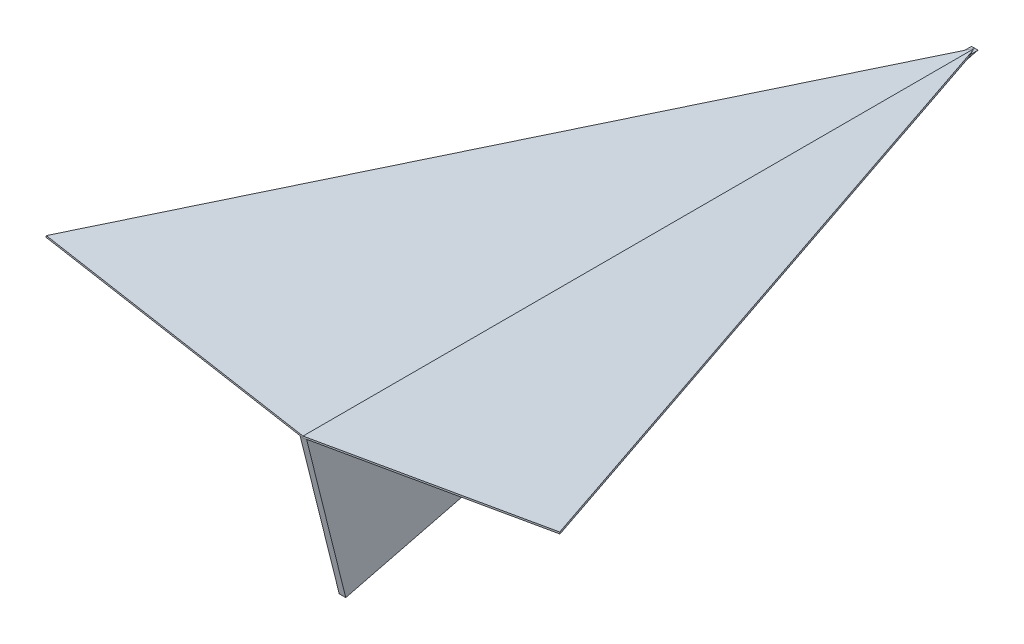
from build123d import *

# Parameters (mm, degrees)
THICKEN_1_T2 = 0.5
THICKEN_2_T2 = 0.5
THICKEN_3_T1 = 1
THICKEN_3_T2 = 1


with BuildPart() as body_1:
    # Sketch 5 → Sheet Plane 1: a flat surface bounded by the sketch
    with BuildSketch(Plane(origin=(0, 0, 0), x_dir=(0, 0, 1), z_dir=(0.17364817766692733, 0.9848077530122086, 0)), mode=Mode.PRIVATE) as sheet_plane_1_1_region:
        Polygon((206.155281281, 0), (206.155281281, -80), (0, 0), align=None)
    sheet_plane_1_1 = sheet_plane_1_1_region.sketch.faces()[0]
    add(Solid.thicken(sheet_plane_1_1, -THICKEN_1_T2))

    # Sketch 4 → Sheet Plane 2: a flat surface bounded by the sketch
    with BuildSketch(Plane(origin=(0, 0, 0), x_dir=(0, 0, 1), z_dir=(-0.173648177666934, 0.9848077530122075, 0)), mode=Mode.PRIVATE) as sheet_plane_2_2_region:
        Polygon((206.155281281, 0), (206.155281281, 80), (0, 0), align=None)
    sheet_plane_2_2 = sheet_plane_2_2_region.sketch.faces()[0]
    add(Solid.thicken(sheet_plane_2_2, -THICKEN_2_T2))

    # Sketch 3 → Sheet Plane 3: a flat surface bounded by the sketch
    with BuildSketch(Plane.YZ, mode=Mode.PRIVATE) as sheet_plane_3_3_region:
        Polygon((0, 0), (0, 206.155281281), (-48.507125007, 194.028500029), align=None)
    sheet_plane_3_3 = sheet_plane_3_3_region.sketch.faces()[0]
    add(Solid.thicken(sheet_plane_3_3, THICKEN_3_T1))
    add(Solid.thicken(sheet_plane_3_3, -THICKEN_3_T2))


solid = body_1.part
